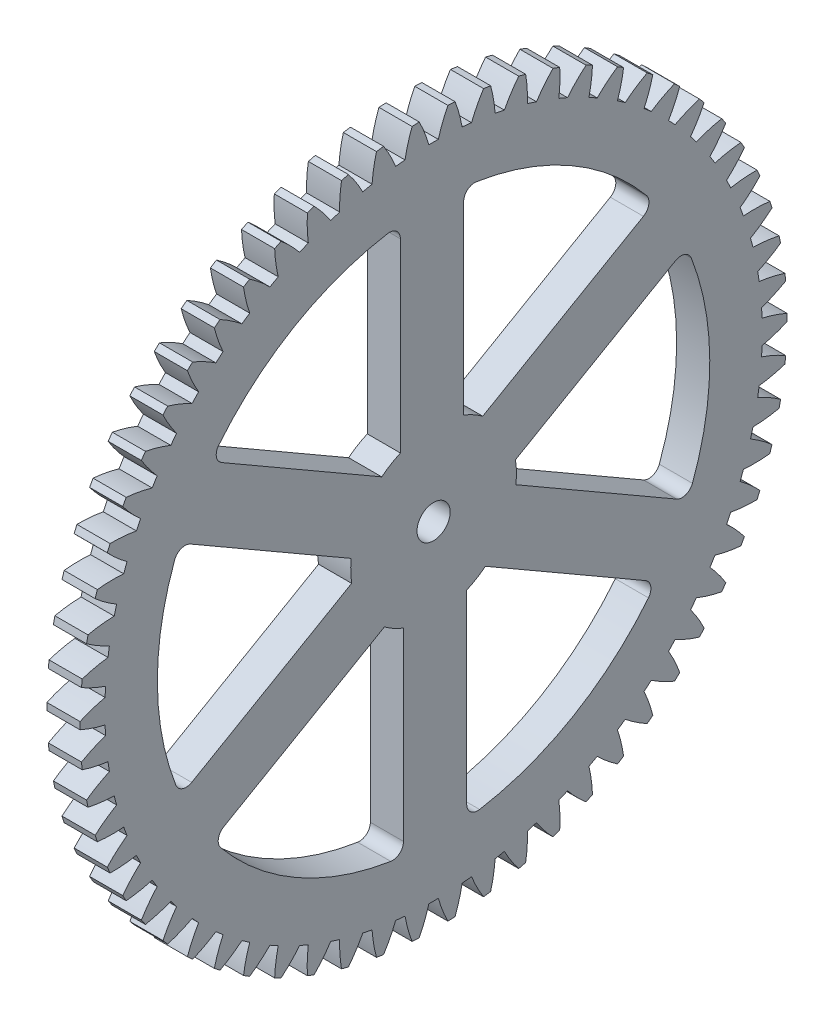
from build123d import *

# Parameters (mm, degrees)
BASPROSKE_W        = 3
BASPROSKE_H        = 32
TOOTHCUT_DEPTH     = 46.354161882
TEETHCUTS_COUNT    = 62
TEETHCUTS_ANGLE    = 354.193548387
BORSKE_R           = 1.5
BORE_DEPTH         = 50.0000508
CUT_EXTRUDE1_DEPTH = 46.335602537
CIRPATTERN1_COUNT  = 6
FILLET1_R          = 1


with BuildPart() as part:
    # BasProSke → Base-Revolve (revolve)
    with BuildSketch(Plane(origin=(0, 0, 0), x_dir=(1, 0, 0), z_dir=(0, 1, 0)), mode=Mode.PRIVATE) as base_revolve_sk:
        with Locations((1.5, 16)):
            Rectangle(BASPROSKE_W, BASPROSKE_H)
    revolve(base_revolve_sk.sketch.rotate(Axis((-10, 0, 0), (1, 0, 0)), 180), axis=Axis((-10, 0, 0), (1, 0, 0)))

    # TooCutSke → ToothCut (cut, through all)
    with BuildSketch(Plane(origin=(0, 0, 0), x_dir=(0, 0, -1), z_dir=(1, 0, 0))):
        with BuildLine():
            ThreePointArc((0.428926933, 29.745907663), (0, 29.749), (-0.428926933, 29.745907663))
            ThreePointArc((-0.428926933, 29.745907663), (-0.814399528, 30.893786924), (-1.30999226, 31.998596304))
            ThreePointArc((-1.30999226, 31.998596304), (0, 32.0254), (1.30999226, 31.998596304))
            ThreePointArc((1.30999226, 31.998596304), (0.814399528, 30.893786924), (0.428926933, 29.745907663))
        make_face()
    toothcut = extrude(amount=TOOTHCUT_DEPTH, mode=Mode.SUBTRACT)

    # TeethCuts: ToothCut ×62 about axis
    teethcuts_axis = Axis((-10, 0, 0), (1, 0, 0))
    for i in range(1, TEETHCUTS_COUNT):
        add(toothcut.rotate(teethcuts_axis, i * TEETHCUTS_ANGLE / (TEETHCUTS_COUNT - 1)), mode=Mode.SUBTRACT)

    # BorSke → Bore (cut, symmetric)
    with BuildSketch(Plane(origin=(0, 0, 0), x_dir=(0, 0, -1), z_dir=(1, 0, 0))):
        with Locations(Location((0, 0, 0), (0, 0, 180))):
            Circle(BORSKE_R)
    extrude(amount=BORE_DEPTH, both=True, mode=Mode.SUBTRACT)

    # Sketch1 → Cut-Extrude1 (cut, through all)
    with BuildSketch(Plane(origin=(3, 0, 0), x_dir=(0, 0, -1), z_dir=(1, 0, 0))):
        with BuildLine():
            Line((-3, 24.819347292), (-3, 6.873863542))
            ThreePointArc((-3, 6.873863542), (-3.879561751, 6.418644765), (-4.691474083, 5.851501596))
            Line((-4.691474083, 5.851501596), (-20.161031757, 14.782854884))
            ThreePointArc((-20.161031757, 14.782854884), (-12.621059503, 21.580288622), (-3, 24.819347292))
        make_face()
    cut_extrude1 = extrude(amount=-CUT_EXTRUDE1_DEPTH, mode=Mode.SUBTRACT)

    # CirPattern1: Cut-Extrude1 ×6 about axis
    cirpattern1_axis = Axis((0, 0, 0), (1, 0, 0))
    for i in range(1, CIRPATTERN1_COUNT):
        add(cut_extrude1.rotate(cirpattern1_axis, i * 360 / CIRPATTERN1_COUNT), mode=Mode.SUBTRACT)

    # Fillet1
    fillet1_edges = [part.edges().sort_by_distance(p)[0] for p in [
        (1.5, 14.782854884, 20.161031757),
        (1.5, 24.819347292, 3),
        (1.5, -24.85139311, 2.721811991),
        (1.5, -15.007749857, 19.99418526),
        (1.5, -10.068538226, 22.882843748),
        (1.5, 9.811597435, 22.99418526),
        (1.5, 10.068538226, -22.882843748),
        (1.5, -9.811597435, -22.99418526),
        (1.5, -14.782854884, -20.161031757),
        (1.5, -24.819347292, -3),
        (1.5, 24.85139311, -2.721811991),
        (1.5, 15.007749857, -19.99418526),
    ]]
    fillet(fillet1_edges, radius=FILLET1_R)


solid = part.part
